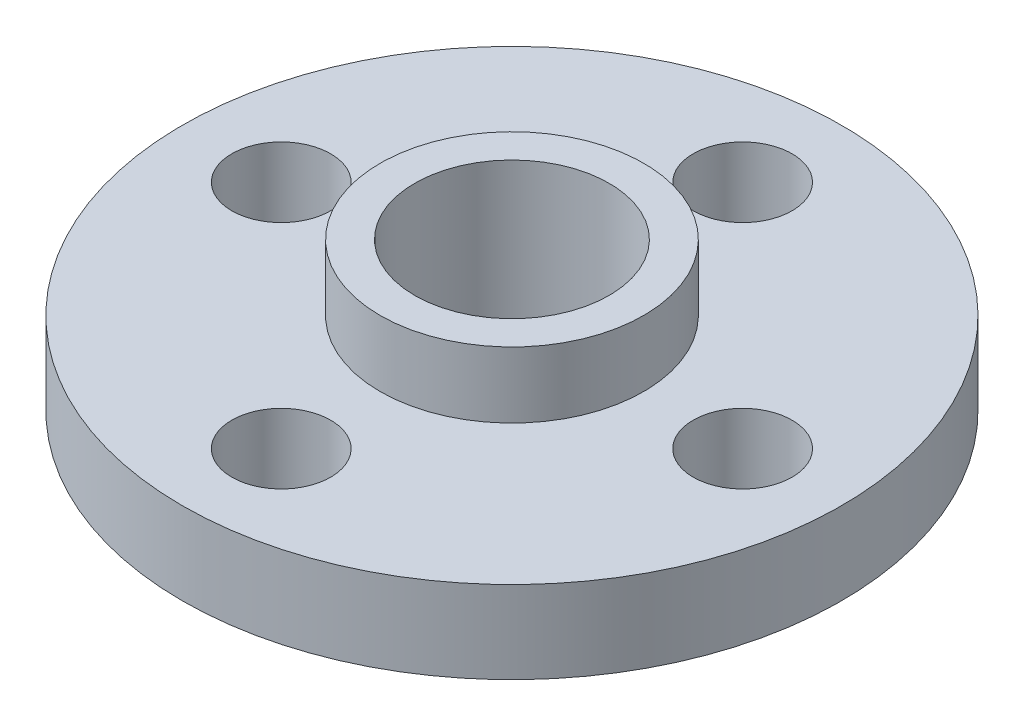
from build123d import *

# Parameters (mm, degrees)
SKETCH_1_R      = 10
SKETCH_1_R_2    = 1.5
SKETCH_1_R_3    = 2.95
EXTRUDE_1_DEPTH = 2.5
SKETCH_2_R      = 4
SKETCH_2_R_2    = 2.95
EXTRUDE_2_DEPTH = 2


with BuildPart() as part:
    # Эскиз1 → Бобышка-Вытянуть1 (new body)
    with BuildSketch(Plane(origin=(0, 0, 0), x_dir=(1, 0, 0), z_dir=(0, 1, 0))):
        Circle(SKETCH_1_R)
        with Locations((-7, 0)):
            Circle(SKETCH_1_R_2, mode=Mode.SUBTRACT)
        with Locations((0, 7)):
            Circle(SKETCH_1_R_2, mode=Mode.SUBTRACT)
        with Locations((0, -7)):
            Circle(SKETCH_1_R_2, mode=Mode.SUBTRACT)
        with Locations((7, 0)):
            Circle(SKETCH_1_R_2, mode=Mode.SUBTRACT)
        Circle(SKETCH_1_R_3, mode=Mode.SUBTRACT)
    extrude(amount=EXTRUDE_1_DEPTH)

    # Эскиз2 → Бобышка-Вытянуть2 (add)
    with BuildSketch(Plane(origin=(0, 2.5, 0), x_dir=(1, 0, 0), z_dir=(0, 1, 0))):
        Circle(SKETCH_2_R)
        Circle(SKETCH_2_R_2, mode=Mode.SUBTRACT)
    extrude(amount=EXTRUDE_2_DEPTH)


solid = part.part
